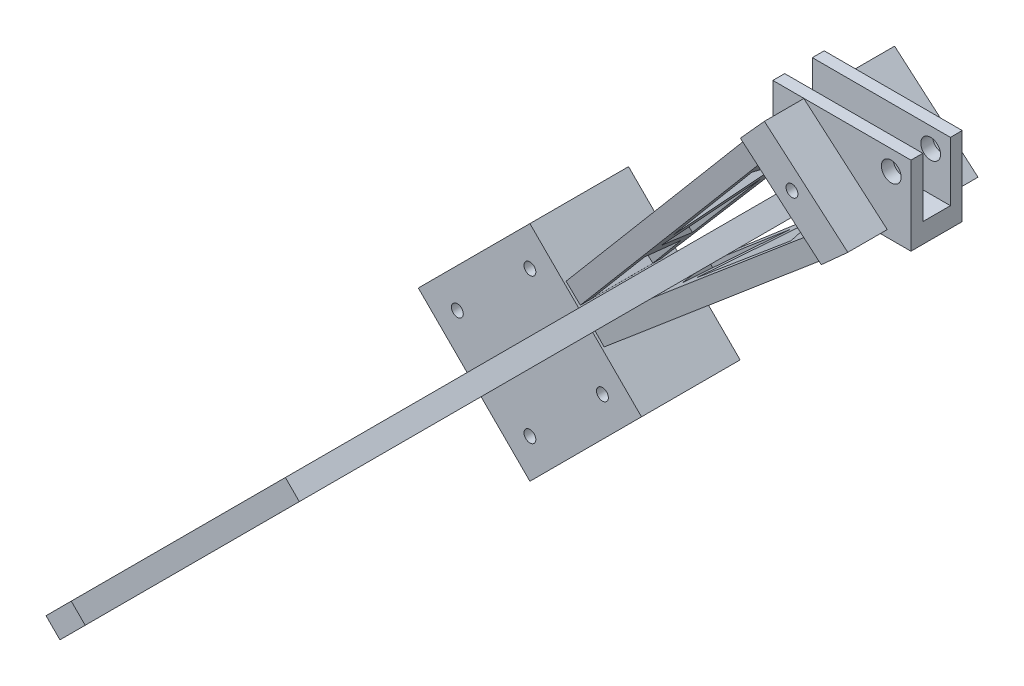
from build123d import *

# Parameters (mm, degrees)
SKETCH10_W               = 35
SKETCH10_H               = 20
BOSS_EXTRUDE9_DEPTH      = 6.5
SKETCH11_W               = 7
SKETCH11_H               = 15
CUT_EXTRUDE4_DEPTH       = 1
CUT_EXTRUDE4_DEPTH_BACK  = 36
BOSS_EXTRUDE10_DEPTH     = 2.5
CUT_EXTRUDE5_DEPTH       = 20
CUT_EXTRUDE6_DEPTH       = 20
BOSS_EXTRUDE11_DEPTH     = 10
SKETCH23_R               = 1.5
CUT_EXTRUDE7_DEPTH       = 34
SKETCH25_R               = 1.5
BOSS_EXTRUDE12_DEPTH     = 12.5
SKETCH27_W               = 7
SKETCH27_H               = 15
CUT_EXTRUDE9_DEPTH       = 20
SKETCH28_W               = 7
SKETCH28_H               = 6.245605743
CUT_EXTRUDE10_DEPTH      = 20
BOSS_EXTRUDE13_DEPTH     = 2.5
BOSS_EXTRUDE14_DEPTH     = 5
SKETCH31_R               = 2.5
CUT_EXTRUDE11_DEPTH      = 44.363432005
CUT_EXTRUDE11_DEPTH_BACK = 111.559122284


with BuildPart() as part:
    # Sketch10 → Boss-Extrude9 (new body, symmetric)
    with BuildSketch(Plane.XY):
        Rectangle(SKETCH10_W, SKETCH10_H)
    extrude(amount=BOSS_EXTRUDE9_DEPTH, both=True)

    # Sketch11 → Cut-Extrude4 (cut, two sides)
    with BuildSketch(Plane.ZY.offset(17.5)) as cut_extrude4_sk:
        with Locations((0, 2.5)):
            Rectangle(SKETCH11_W, SKETCH11_H)
    extrude(amount=CUT_EXTRUDE4_DEPTH, mode=Mode.SUBTRACT)
    extrude(cut_extrude4_sk.sketch, amount=-CUT_EXTRUDE4_DEPTH_BACK, mode=Mode.SUBTRACT)

    # Sketch19 → Boss-Extrude10 (add, symmetric)
    with BuildSketch(Plane(origin=(7.588283472, -8.408592155, 0), x_dir=(-0.742391283, -0.669966553, 0), z_dir=(0.669966553, -0.742391283, 0))):
        Polygon((-6.806611372, 12.5), (-6.806611372, 6.5), (5.959262629, 6.5), (5.959262629, -6.5), (-9.021371158, -6.5), (-9.021371158, -14.5), (143.193388628, 27.210594591), (143.193388628, 47.516269419), align=None)
        Polygon((23.416933748, 15.447357766), (23.416933748, -2.932626146), (48.137832442, 21.788272547), align=None, mode=Mode.SUBTRACT)
        Polygon((34.103204957, 0), (57.455439154, 23.352234198), (87.138773177, 15.447357766), align=None, mode=Mode.SUBTRACT)
        Polygon((69.571415231, 26.355349278), (96.907086696, 19.075671565), (112.271299908, 37.384757918), align=None, mode=Mode.SUBTRACT)
        Polygon((116.606735087, 37.384757918), (103.00206527, 19.075671565), (136.676990559, 28.230214742), (136.676990559, 43.712984767), align=None, mode=Mode.SUBTRACT)
    boss_extrude10 = extrude(amount=BOSS_EXTRUDE10_DEPTH, both=True)

    # Mirror3: Boss-Extrude10 across plane
    add(boss_extrude10.mirror(Plane(origin=(0, 0, 0), x_dir=(0, 0, 1), z_dir=(-0.707106781, 0.707106781, 0))))

    # Sketch20 → Cut-Extrude5 (cut)
    with BuildSketch(Plane(origin=(0, 0, -6.5), x_dir=(-1, 0, 0), z_dir=(0, 0, -1))):
        Polygon((-13.528185403, -10), (16.011199993, 15.429392684), (-17.5, 15.429392684), (-17.5, -10), align=None)
    extrude(amount=CUT_EXTRUDE5_DEPTH, mode=Mode.SUBTRACT)

    # Sketch21 → Cut-Extrude6 (cut)
    with BuildSketch(Plane.XY.offset(6.5)):
        Polygon((-16.011199993, 15.429392684), (13.528185403, -10), (17.5, -10), (17.5, 17.942203717), align=None)
    extrude(amount=CUT_EXTRUDE6_DEPTH, mode=Mode.SUBTRACT)

    # Sketch22 → Boss-Extrude11 (add)
    with BuildSketch(Plane(origin=(0, 0, -6.5), x_dir=(-1, 0, 0), z_dir=(0, 0, -1))):
        Polygon((-4.751258092, -14.336345099), (15.731654079, 3.20511341), (9.645399477, 9.949304357), (-11.495449039, -8.250090497), align=None)
    boss_extrude11 = extrude(amount=BOSS_EXTRUDE11_DEPTH)

    # Mirror5: Boss-Extrude11 across plane
    add(boss_extrude11.mirror(Plane.XY))

    # Sketch23 → Cut-Extrude7 (cut, through all)
    with BuildSketch(Plane(origin=(0, 0, -16.5), x_dir=(-1, 0, 0), z_dir=(0, 0, -1))):
        with Locations((2.661358897, -1.787066196)):
            Circle(SKETCH23_R)
    extrude(amount=-CUT_EXTRUDE7_DEPTH, mode=Mode.SUBTRACT)

    # Sketch25 → Boss-Extrude12 (add, symmetric)
    with BuildSketch(Plane.XY.offset(-37.363432005)):
        Polygon((-110.446046435, -140.151182494), (-82.161775188, -111.866911247), (-110.446046435, -83.582639999), (-138.730317683, -111.866911247), align=None)
        with Locations((-110.446046435, -93.482134936)):
            Circle(SKETCH25_R, mode=Mode.SUBTRACT)
        with Locations((-92.061270124, -111.866911247)):
            Circle(SKETCH25_R, mode=Mode.SUBTRACT)
        with Locations((-110.446046435, -130.251687558)):
            Circle(SKETCH25_R, mode=Mode.SUBTRACT)
        with Locations((-128.830822746, -111.866911247)):
            Circle(SKETCH25_R, mode=Mode.SUBTRACT)
    extrude(amount=BOSS_EXTRUDE12_DEPTH, both=True)

    # Sketch27 → Cut-Extrude9 (cut)
    with BuildSketch(Plane.ZY.offset(17.5)):
        with Locations((0, 2.5)):
            Rectangle(SKETCH27_W, SKETCH27_H)
    extrude(amount=-CUT_EXTRUDE9_DEPTH, mode=Mode.SUBTRACT)

    # Sketch28 → Cut-Extrude10 (cut)
    with BuildSketch(Plane(origin=(-17.5, 0, 0), x_dir=(0, 0, -1), z_dir=(1, 0, 0))):
        with Locations((0, -1.877197128)):
            Rectangle(SKETCH28_W, SKETCH28_H)
    extrude(amount=-CUT_EXTRUDE10_DEPTH, mode=Mode.SUBTRACT)

    # Sketch29 → Boss-Extrude13 (add, symmetric)
    with BuildSketch(Plane(origin=(0.710432406, -0.710432406, 0), x_dir=(0, 0, -1), z_dir=(0.707106781, -0.707106781, 0))):
        Polygon((-19.348604545, -180.98841896), (25.940877716, -162.519522981), (25.940877716, -150.294032198), (-9.701797277, -150.294032198), (-104.059122284, -136.781099823), (-104.059122284, -145.835191948), align=None)
        Polygon((-86.194464325, -143.014000871), (-85.469075751, -150.294032198), (-60.635525341, -147.819595909), align=None, mode=Mode.SUBTRACT)
        Polygon((-77.244001552, -152.888925889), (-36.176017731, -169.28301403), (-51.201535414, -150.294032198), align=None, mode=Mode.SUBTRACT)
        Polygon((15.288083197, -155.48381958), (-9.701797277, -155.48381958), (-16.926790753, -176.046505079), (15.288083197, -162.519522981), align=None, mode=Mode.SUBTRACT)
        Polygon((-23.96640174, -175.703793654), (-44.343704752, -149.951320773), (-16.741408265, -155.141108155), align=None, mode=Mode.SUBTRACT)
        Polygon((25.940877716, -162.519522981), (25.940877716, -150.294032198), (-9.701797277, -150.294032198), (-104.059122284, -136.781099823), (-104.059122284, -145.835191948), (-19.348604545, -180.98841896), align=None)
        Polygon((-51.201535414, -150.294032198), (-36.176017731, -169.28301403), (-77.244001552, -152.888925889), align=None, mode=Mode.SUBTRACT)
        Polygon((-44.343704752, -149.951320773), (-16.741408265, -155.141108155), (-23.96640174, -175.703793654), align=None, mode=Mode.SUBTRACT)
        Polygon((-16.926790753, -176.046505079), (-9.701797277, -155.48381958), (15.288083197, -155.48381958), (15.288083197, -162.519522981), align=None, mode=Mode.SUBTRACT)
        Polygon((-60.635525341, -147.819595909), (-85.469075751, -150.294032198), (-86.194464325, -143.014000871), align=None, mode=Mode.SUBTRACT)
    extrude(amount=BOSS_EXTRUDE13_DEPTH, both=True)

    # Sketch30 → Boss-Extrude14 (add)
    with BuildSketch(Plane(origin=(2.478199359, -2.478199359, 0), x_dir=(0, 0, -1), z_dir=(0.707106781, -0.707106781, 0))):
        Polygon((-41.059122284, -146.781099823), (-2.200668351, -12.59179888), (-4.968563169, -11.790273627), (-44.059122284, -146.781099823), align=None)
    extrude(amount=-BOSS_EXTRUDE14_DEPTH)

    # Sketch31 → Cut-Extrude11 (cut, two sides)
    with BuildSketch(Plane(origin=(0, 0, -6.5), x_dir=(-1, 0, 0), z_dir=(0, 0, -1))) as cut_extrude11_sk:
        with Locations((-12.5, 5)):
            Circle(SKETCH31_R)
    extrude(amount=CUT_EXTRUDE11_DEPTH, mode=Mode.SUBTRACT)
    extrude(cut_extrude11_sk.sketch, amount=-CUT_EXTRUDE11_DEPTH_BACK, mode=Mode.SUBTRACT)


solid = part.part
